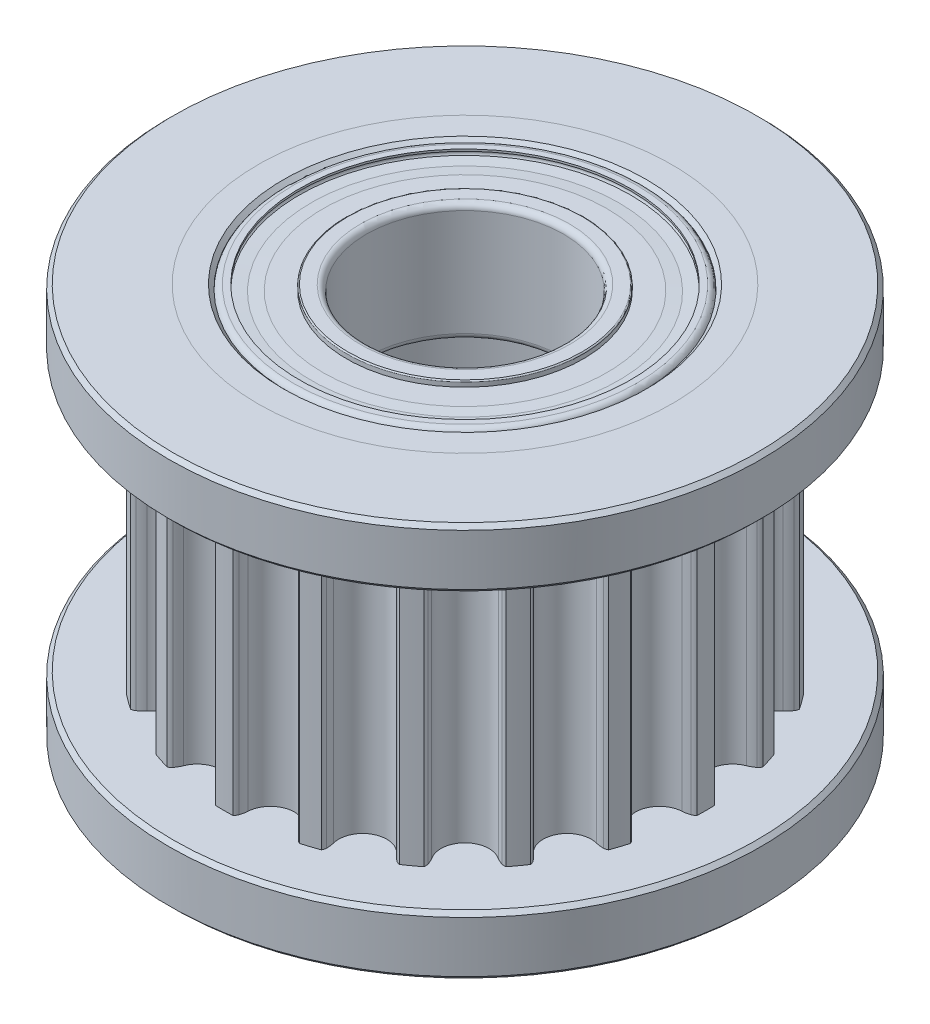
from build123d import *

# Parameters (mm, degrees)
ZKOSEN_1_SIZE            = 0.1
ZAOBLIT1_R               = 0.1
SKICA11_OUTSIDE_W        = 18.214
SKICA11_OUTSIDE_H        = 18.214
ODEBRAT_VYSUNUT_M1_DEPTH = 9.5
SKICA10_R                = 7.5
SKICA10_R_2              = 5.25
P_IDAT_VYSUNUT_M1_DEPTH  = 1.5
SKICA12_R                = 7.5
SKICA12_R_2              = 5.25
P_IDAT_VYSUNUT_M2_DEPTH  = 1.5
ZKOSEN_2_SIZE            = 0.1
ZKOSEN_3_SIZE            = 0.1
KRUHOV_POLE1_COUNT       = 8
KRUHOV_POLE3_COUNT       = 8


with BuildPart() as part:
    # Skica1 → Rotovat1 (revolve)
    with BuildSketch(Plane.XY):
        Polygon((4.5, 10), (5.25, 10), (5.25, 8.5), (6.11, 8.5), (6.11, 1.5), (5.25, 1.5), (5.25, 0), (4.5, 0), (4.5, 3), (3.5, 3), (3.5, 7), (4.5, 7), align=None)
    revolve(axis=Axis((0, 0, 0), (0, -1, 0)))

    # Zkosení1
    zkosen_1_edges = [part.edges().sort_by_distance(p)[0] for p in [
        (-3.5, 3, 0),
        (-4.5, 0, 0),
        (-4.5, 10, 0),
        (-3.5, 7, 0),
    ]]
    chamfer(zkosen_1_edges, length=ZKOSEN_1_SIZE)

    # Zaoblit1
    zaoblit1_edges = [part.edges().sort_by_distance(p)[0] for p in [
        (-4.5, 3, 0),
        (-4.5, 7, 0),
    ]]
    fillet(zaoblit1_edges, radius=ZAOBLIT1_R)

    # Skica11 outside → Odebrat vysunutím1 (cut, through all)
    with BuildSketch(Plane(origin=(0, 8.5, 0), x_dir=(1, 0, 0), z_dir=(0, 1, 0))):
        Rectangle(SKICA11_OUTSIDE_W, SKICA11_OUTSIDE_H)
        with BuildLine():
            ThreePointArc((-3.682382953, -4.525571141), (-3.762727315, -3.762727315), (-4.525571141, -3.682382953))
            ThreePointArc((-4.525571141, -3.682382953), (-4.610021183, -3.728793285), (-4.700326133, -3.762419831))
            ThreePointArc((-4.700326133, -3.762419831), (-4.754288274, -3.771323603), (-4.808820948, -3.767154999))
            ThreePointArc((-4.808820948, -3.767154999), (-4.942042114, -3.590603771), (-5.068784705, -3.409345583))
            ThreePointArc((-5.068784705, -3.409345583), (-5.05589776, -3.356193758), (-5.030754552, -3.307624129))
            ThreePointArc((-5.030754552, -3.307624129), (-4.970868041, -3.232130193), (-4.900632695, -3.166155011))
            ThreePointArc((-4.900632695, -3.166155011), (-4.741313017, -2.415819646), (-5.441992836, -2.103675911))
            ThreePointArc((-5.441992836, -2.103675911), (-5.53665118, -2.121718261), (-5.632927465, -2.125793243))
            ThreePointArc((-5.632927465, -2.125793243), (-5.686999927, -2.117586015), (-5.737575413, -2.096769914))
            ThreePointArc((-5.737575413, -2.096769914), (-5.809718941, -1.887692114), (-5.874246448, -1.676139718))
            ThreePointArc((-5.874246448, -1.676139718), (-5.845565418, -1.629571614), (-5.806643965, -1.591148831))
            ThreePointArc((-5.806643965, -1.591148831), (-5.7263596, -1.53785578), (-5.639174364, -1.496813569))
            ThreePointArc((-5.639174364, -1.496813569), (-5.255785967, -0.832434719), (-5.825714356, -0.319046414))
            ThreePointArc((-5.825714356, -0.319046414), (-5.921315183, -0.306954671), (-6.01413861, -0.281079202))
            ThreePointArc((-6.01413861, -0.281079202), (-6.063028405, -0.256564354), (-6.104696021, -0.221138381))
            ThreePointArc((-6.104696021, -0.221138381), (-6.1087, 0), (-6.104696021, 0.221138381))
            ThreePointArc((-6.104696021, 0.221138381), (-6.063028405, 0.256564354), (-6.01413861, 0.281079202))
            ThreePointArc((-6.01413861, 0.281079202), (-5.921315183, 0.306954671), (-5.825714356, 0.319046414))
            ThreePointArc((-5.825714356, 0.319046414), (-5.255785967, 0.832434719), (-5.639174364, 1.496813569))
            ThreePointArc((-5.639174364, 1.496813569), (-5.7263596, 1.53785578), (-5.806643965, 1.591148831))
            ThreePointArc((-5.806643965, 1.591148831), (-5.845565418, 1.629571614), (-5.874246448, 1.676139718))
            ThreePointArc((-5.874246448, 1.676139718), (-5.809718941, 1.887692114), (-5.737575413, 2.096769914))
            ThreePointArc((-5.737575413, 2.096769914), (-5.686999927, 2.117586015), (-5.632927465, 2.125793243))
            ThreePointArc((-5.632927465, 2.125793243), (-5.53665118, 2.121718261), (-5.441992836, 2.103675911))
            ThreePointArc((-5.441992836, 2.103675911), (-4.741313017, 2.415819646), (-4.900632695, 3.166155011))
            ThreePointArc((-4.900632695, 3.166155011), (-4.970868041, 3.232130193), (-5.030754552, 3.307624129))
            ThreePointArc((-5.030754552, 3.307624129), (-5.05589776, 3.356193758), (-5.068784705, 3.409345583))
            ThreePointArc((-5.068784705, 3.409345583), (-4.942042114, 3.590603771), (-4.808820948, 3.767154999))
            ThreePointArc((-4.808820948, 3.767154999), (-4.754288274, 3.771323603), (-4.700326133, 3.762419831))
            ThreePointArc((-4.700326133, 3.762419831), (-4.610021183, 3.728793285), (-4.525571141, 3.682382953))
            ThreePointArc((-4.525571141, 3.682382953), (-3.762727315, 3.762727315), (-3.682382953, 4.525571141))
            ThreePointArc((-3.682382953, 4.525571141), (-3.728793285, 4.610021183), (-3.762419831, 4.700326133))
            ThreePointArc((-3.762419831, 4.700326133), (-3.771323603, 4.754288274), (-3.767154999, 4.808820948))
            ThreePointArc((-3.767154999, 4.808820948), (-3.590603771, 4.942042114), (-3.409345583, 5.068784705))
            ThreePointArc((-3.409345583, 5.068784705), (-3.356193758, 5.05589776), (-3.307624129, 5.030754552))
            ThreePointArc((-3.307624129, 5.030754552), (-3.232130193, 4.970868041), (-3.166155011, 4.900632695))
            ThreePointArc((-3.166155011, 4.900632695), (-2.415819646, 4.741313017), (-2.103675911, 5.441992836))
            ThreePointArc((-2.103675911, 5.441992836), (-2.121718261, 5.53665118), (-2.125793243, 5.632927465))
            ThreePointArc((-2.125793243, 5.632927465), (-2.117586015, 5.686999927), (-2.096769914, 5.737575413))
            ThreePointArc((-2.096769914, 5.737575413), (-1.887692114, 5.809718941), (-1.676139718, 5.874246448))
            ThreePointArc((-1.676139718, 5.874246448), (-1.629571614, 5.845565418), (-1.591148831, 5.806643965))
            ThreePointArc((-1.591148831, 5.806643965), (-1.53785578, 5.7263596), (-1.496813569, 5.639174364))
            ThreePointArc((-1.496813569, 5.639174364), (-0.832434719, 5.255785967), (-0.319046414, 5.825714356))
            ThreePointArc((-0.319046414, 5.825714356), (-0.306954671, 5.921315183), (-0.281079202, 6.01413861))
            ThreePointArc((-0.281079202, 6.01413861), (-0.256564354, 6.063028405), (-0.221138381, 6.104696021))
            ThreePointArc((-0.221138381, 6.104696021), (0, 6.1087), (0.221138381, 6.104696021))
            ThreePointArc((0.221138381, 6.104696021), (0.256564354, 6.063028405), (0.281079202, 6.01413861))
            ThreePointArc((0.281079202, 6.01413861), (0.306954671, 5.921315183), (0.319046414, 5.825714356))
            ThreePointArc((0.319046414, 5.825714356), (0.832434719, 5.255785967), (1.496813569, 5.639174364))
            ThreePointArc((1.496813569, 5.639174364), (1.53785578, 5.7263596), (1.591148831, 5.806643965))
            ThreePointArc((1.591148831, 5.806643965), (1.629571614, 5.845565418), (1.676139718, 5.874246448))
            ThreePointArc((1.676139718, 5.874246448), (1.887692114, 5.809718941), (2.096769914, 5.737575413))
            ThreePointArc((2.096769914, 5.737575413), (2.117586015, 5.686999927), (2.125793243, 5.632927465))
            ThreePointArc((2.125793243, 5.632927465), (2.121718261, 5.53665118), (2.103675911, 5.441992836))
            ThreePointArc((2.103675911, 5.441992836), (2.415819646, 4.741313017), (3.166155011, 4.900632695))
            ThreePointArc((3.166155011, 4.900632695), (3.232130193, 4.970868041), (3.307624129, 5.030754552))
            ThreePointArc((3.307624129, 5.030754552), (3.356193758, 5.05589776), (3.409345583, 5.068784705))
            ThreePointArc((3.409345583, 5.068784705), (3.590603771, 4.942042114), (3.767154999, 4.808820948))
            ThreePointArc((3.767154999, 4.808820948), (3.771323603, 4.754288274), (3.762419831, 4.700326133))
            ThreePointArc((3.762419831, 4.700326133), (3.728793285, 4.610021183), (3.682382953, 4.525571141))
            ThreePointArc((3.682382953, 4.525571141), (3.762727315, 3.762727315), (4.525571141, 3.682382953))
            ThreePointArc((4.525571141, 3.682382953), (4.610021183, 3.728793285), (4.700326133, 3.762419831))
            ThreePointArc((4.700326133, 3.762419831), (4.754288273, 3.771323603), (4.808820948, 3.767154999))
            ThreePointArc((4.808820948, 3.767154999), (4.942042114, 3.590603771), (5.068784705, 3.409345583))
            ThreePointArc((5.068784705, 3.409345583), (5.05589776, 3.356193758), (5.030754552, 3.307624129))
            ThreePointArc((5.030754552, 3.307624129), (4.970868041, 3.232130193), (4.900632695, 3.166155011))
            ThreePointArc((4.900632695, 3.166155011), (4.741313017, 2.415819646), (5.441992836, 2.103675911))
            ThreePointArc((5.441992836, 2.103675911), (5.53665118, 2.121718261), (5.632927465, 2.125793243))
            ThreePointArc((5.632927465, 2.125793243), (5.686999927, 2.117586015), (5.737575413, 2.096769914))
            ThreePointArc((5.737575413, 2.096769914), (5.809718941, 1.887692114), (5.874246448, 1.676139718))
            ThreePointArc((5.874246448, 1.676139718), (5.845565418, 1.629571614), (5.806643965, 1.591148831))
            ThreePointArc((5.806643965, 1.591148831), (5.7263596, 1.53785578), (5.639174364, 1.496813569))
            ThreePointArc((5.639174364, 1.496813569), (5.255785967, 0.832434719), (5.825714356, 0.319046414))
            ThreePointArc((5.825714356, 0.319046414), (5.921315183, 0.306954671), (6.01413861, 0.281079202))
            ThreePointArc((6.01413861, 0.281079202), (6.063028405, 0.256564354), (6.104696021, 0.221138381))
            ThreePointArc((6.104696021, 0.221138381), (6.1087, 0), (6.104696021, -0.221138381))
            ThreePointArc((6.104696021, -0.221138381), (6.063028405, -0.256564354), (6.01413861, -0.281079202))
            ThreePointArc((6.01413861, -0.281079202), (5.921315183, -0.306954671), (5.825714356, -0.319046414))
            ThreePointArc((5.825714356, -0.319046414), (5.255785967, -0.832434719), (5.639174364, -1.496813569))
            ThreePointArc((5.639174364, -1.496813569), (5.7263596, -1.53785578), (5.806643965, -1.591148831))
            ThreePointArc((5.806643965, -1.591148831), (5.845565418, -1.629571614), (5.874246448, -1.676139718))
            ThreePointArc((5.874246448, -1.676139718), (5.809718941, -1.887692114), (5.737575413, -2.096769914))
            ThreePointArc((5.737575413, -2.096769914), (5.686999927, -2.117586015), (5.632927465, -2.125793243))
            ThreePointArc((5.632927465, -2.125793243), (5.53665118, -2.121718261), (5.441992836, -2.103675911))
            ThreePointArc((5.441992836, -2.103675911), (4.741313017, -2.415819646), (4.900632695, -3.166155011))
            ThreePointArc((4.900632695, -3.166155011), (4.970868041, -3.232130193), (5.030754552, -3.307624129))
            ThreePointArc((5.030754552, -3.307624129), (5.05589776, -3.356193758), (5.068784705, -3.409345583))
            ThreePointArc((5.068784705, -3.409345583), (4.942042114, -3.590603771), (4.808820948, -3.767154999))
            ThreePointArc((4.808820948, -3.767154999), (4.754288273, -3.771323603), (4.700326133, -3.762419831))
            ThreePointArc((4.700326133, -3.762419831), (4.610021183, -3.728793285), (4.525571141, -3.682382953))
            ThreePointArc((4.525571141, -3.682382953), (3.762727315, -3.762727315), (3.682382953, -4.525571141))
            ThreePointArc((3.682382953, -4.525571141), (3.728793285, -4.610021183), (3.762419831, -4.700326133))
            ThreePointArc((3.762419831, -4.700326133), (3.771323603, -4.754288274), (3.767154999, -4.808820948))
            ThreePointArc((3.767154999, -4.808820948), (3.590603771, -4.942042114), (3.409345583, -5.068784705))
            ThreePointArc((3.409345583, -5.068784705), (3.356193758, -5.05589776), (3.307624129, -5.030754552))
            ThreePointArc((3.307624129, -5.030754552), (3.232130193, -4.970868041), (3.166155011, -4.900632695))
            ThreePointArc((3.166155011, -4.900632695), (2.415819646, -4.741313017), (2.103675911, -5.441992836))
            ThreePointArc((2.103675911, -5.441992836), (2.121718261, -5.53665118), (2.125793243, -5.632927465))
            ThreePointArc((2.125793243, -5.632927465), (2.117586015, -5.686999927), (2.096769914, -5.737575413))
            ThreePointArc((2.096769914, -5.737575413), (1.887692114, -5.809718941), (1.676139718, -5.874246448))
            ThreePointArc((1.676139718, -5.874246448), (1.629571614, -5.845565418), (1.591148831, -5.806643965))
            ThreePointArc((1.591148831, -5.806643965), (1.53785578, -5.7263596), (1.496813569, -5.639174364))
            ThreePointArc((1.496813569, -5.639174364), (0.832434719, -5.255785967), (0.319046414, -5.825714356))
            ThreePointArc((0.319046414, -5.825714356), (0.306954671, -5.921315183), (0.281079202, -6.01413861))
            ThreePointArc((0.281079202, -6.01413861), (0.256564354, -6.063028405), (0.221138381, -6.104696021))
            ThreePointArc((0.221138381, -6.104696021), (0, -6.1087), (-0.221138381, -6.104696021))
            ThreePointArc((-0.221138381, -6.104696021), (-0.256564354, -6.063028405), (-0.281079202, -6.01413861))
            ThreePointArc((-0.281079202, -6.01413861), (-0.306954671, -5.921315183), (-0.319046414, -5.825714356))
            ThreePointArc((-0.319046414, -5.825714356), (-0.832434719, -5.255785967), (-1.496813569, -5.639174364))
            ThreePointArc((-1.496813569, -5.639174364), (-1.53785578, -5.7263596), (-1.591148831, -5.806643965))
            ThreePointArc((-1.591148831, -5.806643965), (-1.629571614, -5.845565418), (-1.676139718, -5.874246448))
            ThreePointArc((-1.676139718, -5.874246448), (-1.887692114, -5.809718941), (-2.096769914, -5.737575413))
            ThreePointArc((-2.096769914, -5.737575413), (-2.117586015, -5.686999927), (-2.125793243, -5.632927465))
            ThreePointArc((-2.125793243, -5.632927465), (-2.121718261, -5.53665118), (-2.103675911, -5.441992836))
            ThreePointArc((-2.103675911, -5.441992836), (-2.415819646, -4.741313017), (-3.166155011, -4.900632695))
            ThreePointArc((-3.166155011, -4.900632695), (-3.232130193, -4.970868041), (-3.307624129, -5.030754552))
            ThreePointArc((-3.307624129, -5.030754552), (-3.356193758, -5.05589776), (-3.409345583, -5.068784705))
            ThreePointArc((-3.409345583, -5.068784705), (-3.590603771, -4.942042114), (-3.767154999, -4.808820948))
            ThreePointArc((-3.767154999, -4.808820948), (-3.771323603, -4.754288274), (-3.762419831, -4.700326133))
            ThreePointArc((-3.762419831, -4.700326133), (-3.728793285, -4.610021183), (-3.682382953, -4.525571141))
        make_face(mode=Mode.SUBTRACT)
    extrude(amount=-ODEBRAT_VYSUNUT_M1_DEPTH, mode=Mode.SUBTRACT)


with BuildPart() as body_2:
    # Skica10 → Přidat vysunutím1 (new body)
    with BuildSketch(Plane(origin=(0, 10, 0), x_dir=(1, 0, 0), z_dir=(0, 1, 0))):
        Circle(SKICA10_R)
        Circle(SKICA10_R_2, mode=Mode.SUBTRACT)
    extrude(amount=-P_IDAT_VYSUNUT_M1_DEPTH)

    # Zkosení2
    zkosen_2_edges = [body_2.edges().sort_by_distance(p)[0] for p in [
        (-7.5, 10, 0),
        (-7.5, 8.5, 0),
    ]]
    chamfer(zkosen_2_edges, length=ZKOSEN_2_SIZE)


with BuildPart() as body_3:
    # Skica12 → Přidat vysunutím2 (new body)
    with BuildSketch(Plane.XZ):
        Circle(SKICA12_R)
        Circle(SKICA12_R_2, mode=Mode.SUBTRACT)
    extrude(amount=-P_IDAT_VYSUNUT_M2_DEPTH)

    # Zkosení3
    zkosen_3_edges = [body_3.edges().sort_by_distance(p)[0] for p in [
        (-7.5, 0, 0),
        (-7.5, 1.5, 0),
    ]]
    chamfer(zkosen_3_edges, length=ZKOSEN_3_SIZE)


with BuildPart() as body_4:
    # Skica4 → Rotovat2 (revolve)
    with BuildSketch(Plane.XY):
        with BuildLine():
            Line((4.5, 9.85), (4.5, 7.15))
            ThreePointArc((4.5, 7.15), (4.456066017, 7.043933983), (4.35, 7))
            Line((4.35, 7), (4.2, 7))
            Line((4.2, 7), (4.2, 7.05))
            ThreePointArc((4.2, 7.05), (4.289757174, 7.133393211), (4.213177928, 7.229030007))
            Line((4.213177928, 7.229030007), (3.85, 7.282786405))
            Line((3.85, 7.282786405), (3.85, 8.052786405))
            ThreePointArc((3.85, 8.052786405), (4.05, 8.5), (3.85, 8.947213595))
            Line((3.85, 8.947213595), (3.85, 9.717213595))
            Line((3.85, 9.717213595), (4.213177928, 9.770969993))
            ThreePointArc((4.213177928, 9.770969993), (4.289757174, 9.866606789), (4.2, 9.95))
            Line((4.2, 9.95), (4.2, 10))
            Line((4.2, 10), (4.35, 10))
            ThreePointArc((4.35, 10), (4.456066017, 9.956066017), (4.5, 9.85))
        make_face()
    revolve(axis=Axis((0, 0, 0), (0, 1, 0)))


with BuildPart() as body_5:
    # Skica5 → Rotovat3 (revolve)
    with BuildSketch(Plane.XY):
        with BuildLine():
            Line((2.5, 9.85), (2.5, 7.15))
            ThreePointArc((2.5, 7.15), (2.543933983, 7.043933983), (2.65, 7))
            Line((2.65, 7), (2.97, 7))
            ThreePointArc((2.97, 7), (2.991213203, 7.008786797), (3, 7.03))
            Line((3, 7.03), (3, 7.14))
            Line((3, 7.14), (3.6, 7.14))
            Line((3.6, 7.14), (3.896185034, 7.191714847))
            Line((3.896185034, 7.191714847), (4.192370069, 7.14))
            Line((4.192370069, 7.14), (4.192370069, 7.19))
            Line((4.192370069, 7.19), (3.897467562, 7.258062558))
            Line((3.897467562, 7.258062558), (3.597467562, 7.258062558))
            Line((3.597467562, 7.258062558), (3, 7.19))
            Line((3, 7.19), (3, 8.103137303))
            ThreePointArc((3, 8.103137303), (2.85, 8.5), (3, 8.896862697))
            Line((3, 8.896862697), (3, 9.81))
            Line((3, 9.81), (3.6, 9.77))
            Line((3.6, 9.77), (3.9, 9.77))
            Line((3.9, 9.77), (4.2, 9.81))
            Line((4.2, 9.81), (4.2, 9.86))
            Line((4.2, 9.86), (3.9, 9.84))
            Line((3.9, 9.84), (3.6, 9.86))
            Line((3.6, 9.86), (3, 9.86))
            Line((3, 9.86), (3, 9.97))
            ThreePointArc((3, 9.97), (2.991213203, 9.991213203), (2.97, 10))
            Line((2.97, 10), (2.65, 10))
            ThreePointArc((2.65, 10), (2.543933983, 9.956066017), (2.5, 9.85))
        make_face()
    revolve(axis=Axis((0, 0, 0), (0, 1, 0)))


with BuildPart() as body_6:
    # Skica6 → Rotovat4 (revolve)
    with BuildSketch(Plane.XY):
        with BuildLine():
            Line((3.45, 9.1), (3.45, 7.9))
            ThreePointArc((3.45, 7.9), (4.05, 8.5), (3.45, 9.1))
        make_face()
    revolve(axis=Axis((3.45, 9.1, 0), (0, -1, 0)))


with BuildPart() as kruhov_pole1_1:
    # Kruhové pole1: pattern copy
    add(body_6.part.rotate(Axis((0, 0, 0), (0, 1, 0)), 1 * 360 / KRUHOV_POLE1_COUNT))


with BuildPart() as kruhov_pole1_2:
    # Kruhové pole1: pattern copy
    add(body_6.part.rotate(Axis((0, 0, 0), (0, 1, 0)), 2 * 360 / KRUHOV_POLE1_COUNT))


with BuildPart() as kruhov_pole1_3:
    # Kruhové pole1: pattern copy
    add(body_6.part.rotate(Axis((0, 0, 0), (0, 1, 0)), 3 * 360 / KRUHOV_POLE1_COUNT))


with BuildPart() as kruhov_pole1_4:
    # Kruhové pole1: pattern copy
    add(body_6.part.rotate(Axis((0, 0, 0), (0, 1, 0)), 4 * 360 / KRUHOV_POLE1_COUNT))


with BuildPart() as kruhov_pole1_5:
    # Kruhové pole1: pattern copy
    add(body_6.part.rotate(Axis((0, 0, 0), (0, 1, 0)), 5 * 360 / KRUHOV_POLE1_COUNT))


with BuildPart() as kruhov_pole1_6:
    # Kruhové pole1: pattern copy
    add(body_6.part.rotate(Axis((0, 0, 0), (0, 1, 0)), 6 * 360 / KRUHOV_POLE1_COUNT))


with BuildPart() as kruhov_pole1_7:
    # Kruhové pole1: pattern copy
    add(body_6.part.rotate(Axis((0, 0, 0), (0, 1, 0)), 7 * 360 / KRUHOV_POLE1_COUNT))


with BuildPart() as body_14:
    # Skica7 → Rotovat5 (revolve)
    with BuildSketch(Plane.XY):
        with BuildLine():
            Line((4.5, 2.85), (4.5, 0.15))
            ThreePointArc((4.5, 0.15), (4.456066017, 0.043933983), (4.35, 0))
            Line((4.35, 0), (4.2, 0))
            Line((4.2, 0), (4.2, 0.05))
            ThreePointArc((4.2, 0.05), (4.289757174, 0.133393211), (4.213177928, 0.229030007))
            Line((4.213177928, 0.229030007), (3.85, 0.282786405))
            Line((3.85, 0.282786405), (3.85, 1.052786405))
            ThreePointArc((3.85, 1.052786405), (4.05, 1.5), (3.85, 1.947213595))
            Line((3.85, 1.947213595), (3.85, 2.717213595))
            Line((3.85, 2.717213595), (4.213177928, 2.770969993))
            ThreePointArc((4.213177928, 2.770969993), (4.289757174, 2.866606789), (4.2, 2.95))
            Line((4.2, 2.95), (4.2, 3))
            Line((4.2, 3), (4.35, 3))
            ThreePointArc((4.35, 3), (4.456066017, 2.956066017), (4.5, 2.85))
        make_face()
    revolve(axis=Axis((0, 0, 0), (0, 1, 0)))


with BuildPart() as body_15:
    # Skica8 → Rotovat6 (revolve)
    with BuildSketch(Plane.XY):
        with BuildLine():
            Line((2.5, 2.85), (2.5, 0.15))
            ThreePointArc((2.5, 0.15), (2.543933983, 0.043933983), (2.65, 0))
            Line((2.65, 0), (2.97, 0))
            ThreePointArc((2.97, 0), (2.991213203, 0.008786797), (3, 0.03))
            Line((3, 0.03), (3, 0.14))
            Line((3, 0.14), (3.6, 0.14))
            Line((3.6, 0.14), (3.896185034, 0.191714847))
            Line((3.896185034, 0.191714847), (4.192370069, 0.14))
            Line((4.192370069, 0.14), (4.192370069, 0.19))
            Line((4.192370069, 0.19), (3.897467562, 0.258062558))
            Line((3.897467562, 0.258062558), (3.597467562, 0.258062558))
            Line((3.597467562, 0.258062558), (3, 0.19))
            Line((3, 0.19), (3, 1.103137303))
            ThreePointArc((3, 1.103137303), (2.85, 1.5), (3, 1.896862697))
            Line((3, 1.896862697), (3, 2.81))
            Line((3, 2.81), (3.6, 2.77))
            Line((3.6, 2.77), (3.9, 2.77))
            Line((3.9, 2.77), (4.2, 2.81))
            Line((4.2, 2.81), (4.2, 2.86))
            Line((4.2, 2.86), (3.9, 2.84))
            Line((3.9, 2.84), (3.6, 2.86))
            Line((3.6, 2.86), (3, 2.86))
            Line((3, 2.86), (3, 2.97))
            ThreePointArc((3, 2.97), (2.991213203, 2.991213203), (2.97, 3))
            Line((2.97, 3), (2.65, 3))
            ThreePointArc((2.65, 3), (2.543933983, 2.956066017), (2.5, 2.85))
        make_face()
    revolve(axis=Axis((0, 0, 0), (0, -1, 0)))


with BuildPart() as body_16:
    # Skica9 → Rotovat7 (revolve)
    with BuildSketch(Plane.XY):
        with BuildLine():
            Line((3.45, 2.1), (3.45, 0.9))
            ThreePointArc((3.45, 0.9), (4.05, 1.5), (3.45, 2.1))
        make_face()
    revolve(axis=Axis((3.45, 2.1, 0), (0, -1, 0)))


with BuildPart() as kruhov_pole3_1:
    # Kruhové pole3: pattern copy
    add(body_16.part.rotate(Axis((0, 0, 0), (0, 1, 0)), 1 * 360 / KRUHOV_POLE3_COUNT))


with BuildPart() as kruhov_pole3_2:
    # Kruhové pole3: pattern copy
    add(body_16.part.rotate(Axis((0, 0, 0), (0, 1, 0)), 2 * 360 / KRUHOV_POLE3_COUNT))


with BuildPart() as kruhov_pole3_3:
    # Kruhové pole3: pattern copy
    add(body_16.part.rotate(Axis((0, 0, 0), (0, 1, 0)), 3 * 360 / KRUHOV_POLE3_COUNT))


with BuildPart() as kruhov_pole3_4:
    # Kruhové pole3: pattern copy
    add(body_16.part.rotate(Axis((0, 0, 0), (0, 1, 0)), 4 * 360 / KRUHOV_POLE3_COUNT))


with BuildPart() as kruhov_pole3_5:
    # Kruhové pole3: pattern copy
    add(body_16.part.rotate(Axis((0, 0, 0), (0, 1, 0)), 5 * 360 / KRUHOV_POLE3_COUNT))


with BuildPart() as kruhov_pole3_6:
    # Kruhové pole3: pattern copy
    add(body_16.part.rotate(Axis((0, 0, 0), (0, 1, 0)), 6 * 360 / KRUHOV_POLE3_COUNT))


with BuildPart() as kruhov_pole3_7:
    # Kruhové pole3: pattern copy
    add(body_16.part.rotate(Axis((0, 0, 0), (0, 1, 0)), 7 * 360 / KRUHOV_POLE3_COUNT))


solid = Compound([part.part, body_2.part, body_3.part, body_4.part, body_5.part, body_6.part, kruhov_pole1_1.part, kruhov_pole1_2.part, kruhov_pole1_3.part, kruhov_pole1_4.part, kruhov_pole1_5.part, kruhov_pole1_6.part, kruhov_pole1_7.part, body_14.part, body_15.part, body_16.part, kruhov_pole3_1.part, kruhov_pole3_2.part, kruhov_pole3_3.part, kruhov_pole3_4.part, kruhov_pole3_5.part, kruhov_pole3_6.part, kruhov_pole3_7.part])
